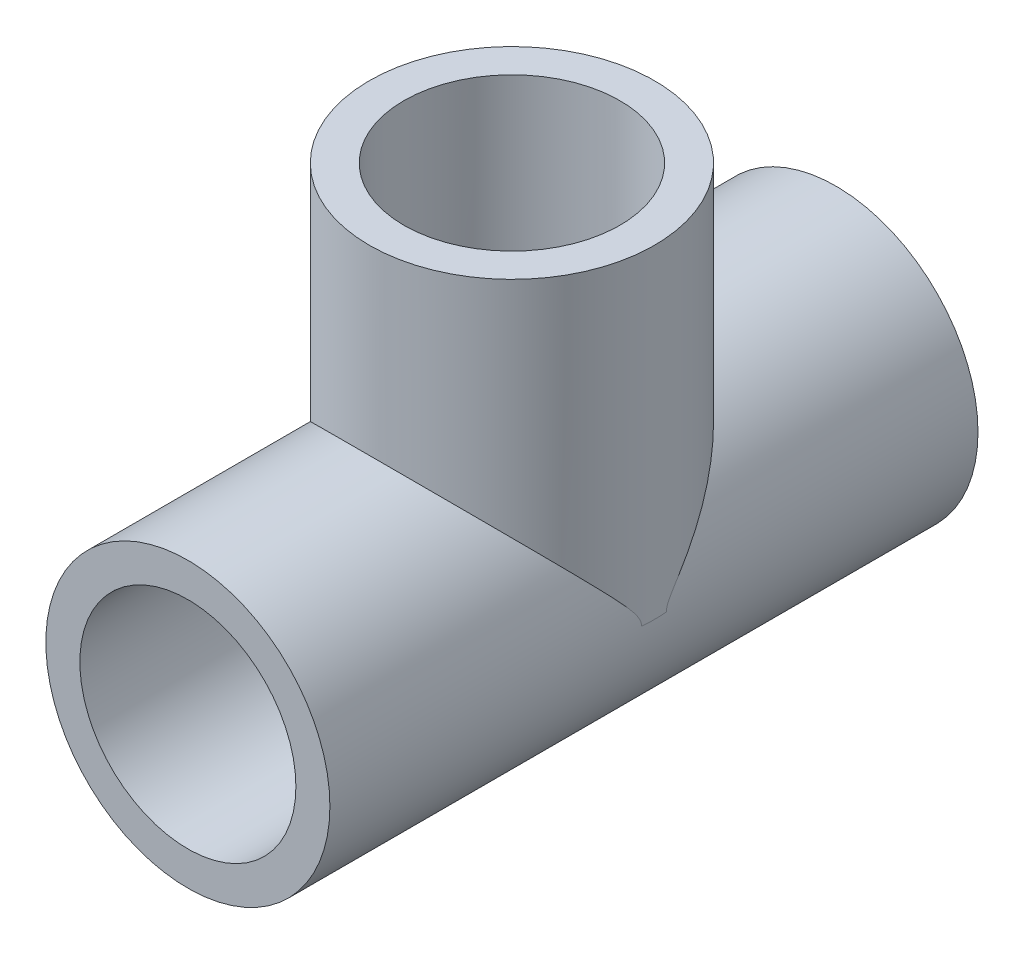
from build123d import *

# Parameters (mm, degrees)
SKETCH1_R           = 16.7005
SKETCH1_R_2         = 12.7
BOSS_EXTRUDE1_DEPTH = 76.2
SKETCH2_R           = 16.764
SKETCH2_R_2         = 12.7
BOSS_EXTRUDE2_DEPTH = 38.1
SKETCH4_R           = 12.7
CUT_EXTRUDE2_DEPTH  = 77.2000001
CUT_EXTRUDE3_REACH  = 56.801
SKETCH5_R           = 12.7


with BuildPart() as part:
    # Sketch1 → Boss-Extrude1 (new body)
    with BuildSketch(Plane.XY):
        Circle(SKETCH1_R)
        Circle(SKETCH1_R_2, mode=Mode.SUBTRACT)
    extrude(amount=BOSS_EXTRUDE1_DEPTH)

    # Sketch2 → Boss-Extrude2 (add)
    with BuildSketch(Plane(origin=(0, 0, 0), x_dir=(1, 0, 0), z_dir=(0, 1, 0))):
        with Locations((0, -38.1)):
            Circle(SKETCH2_R)
        with Locations((0, -38.1)):
            Circle(SKETCH2_R_2, mode=Mode.SUBTRACT)
    extrude(amount=BOSS_EXTRUDE2_DEPTH)

    # Sketch4 → Cut-Extrude2 (cut, through all)
    with BuildSketch(Plane.XY.offset(76.2)):
        Circle(SKETCH4_R)
    extrude(amount=-CUT_EXTRUDE2_DEPTH, mode=Mode.SUBTRACT)

    # Sketch5 → Cut-Extrude3 (cut, up to next)
    with BuildSketch(Plane(origin=(0, 38.1, 0), x_dir=(1, 0, 0), z_dir=(0, 1, 0)), mode=Mode.PRIVATE) as cut_extrude3_sk1:
        with Locations((0, -38.1)):
            Circle(SKETCH5_R)
    cut_extrude3_tool1 = extrude(cut_extrude3_sk1.sketch, amount=-CUT_EXTRUDE3_REACH, mode=Mode.PRIVATE) & part.part
    add(cut_extrude3_tool1.solids().sort_by_distance((0, 38.1, 38.1))[0], mode=Mode.SUBTRACT)


solid = part.part
